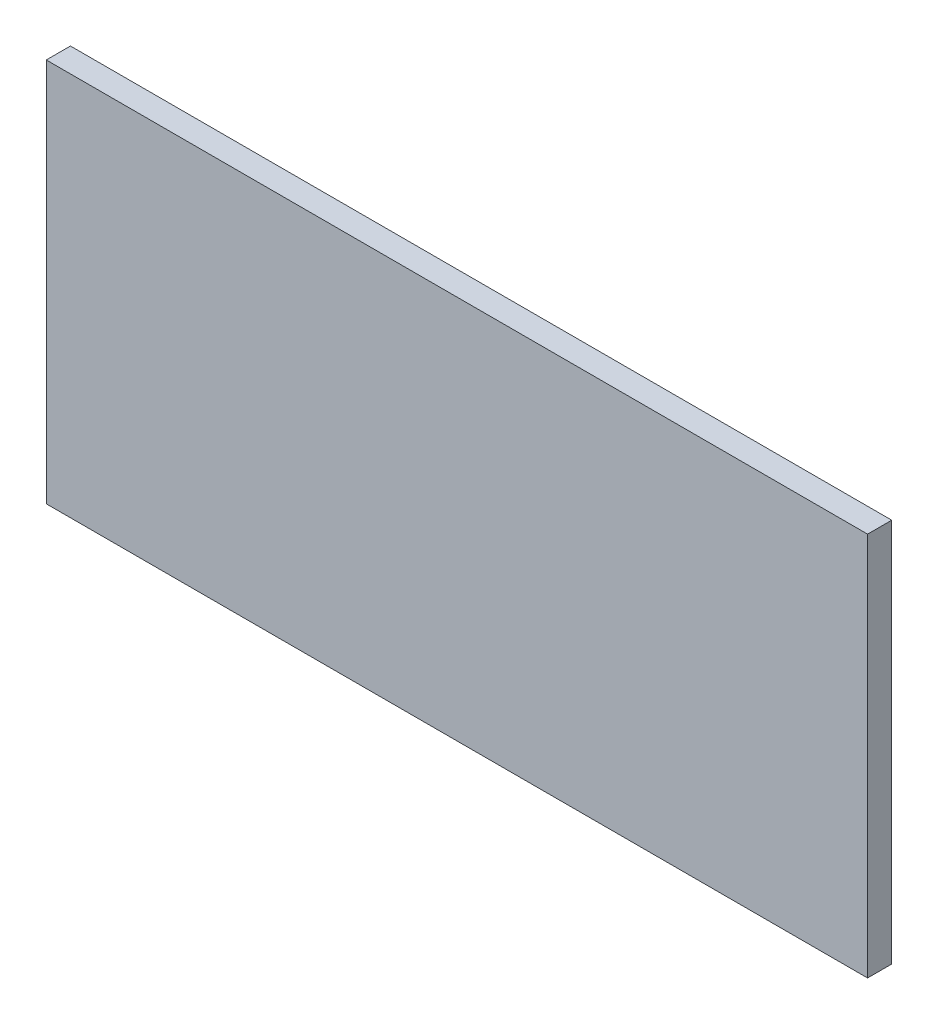
from build123d import *

# Parameters (mm, degrees)
SKETCH1_W           = 107.95
SKETCH1_H           = 50.525
BOSS_EXTRUDE1_DEPTH = 3.175


with BuildPart() as part:
    # Sketch1 → Boss-Extrude1 (new body)
    with BuildSketch(Plane.XY):
        with Locations((50.8, -25.2625)):
            Rectangle(SKETCH1_W, SKETCH1_H)
    extrude(amount=BOSS_EXTRUDE1_DEPTH)


solid = part.part
